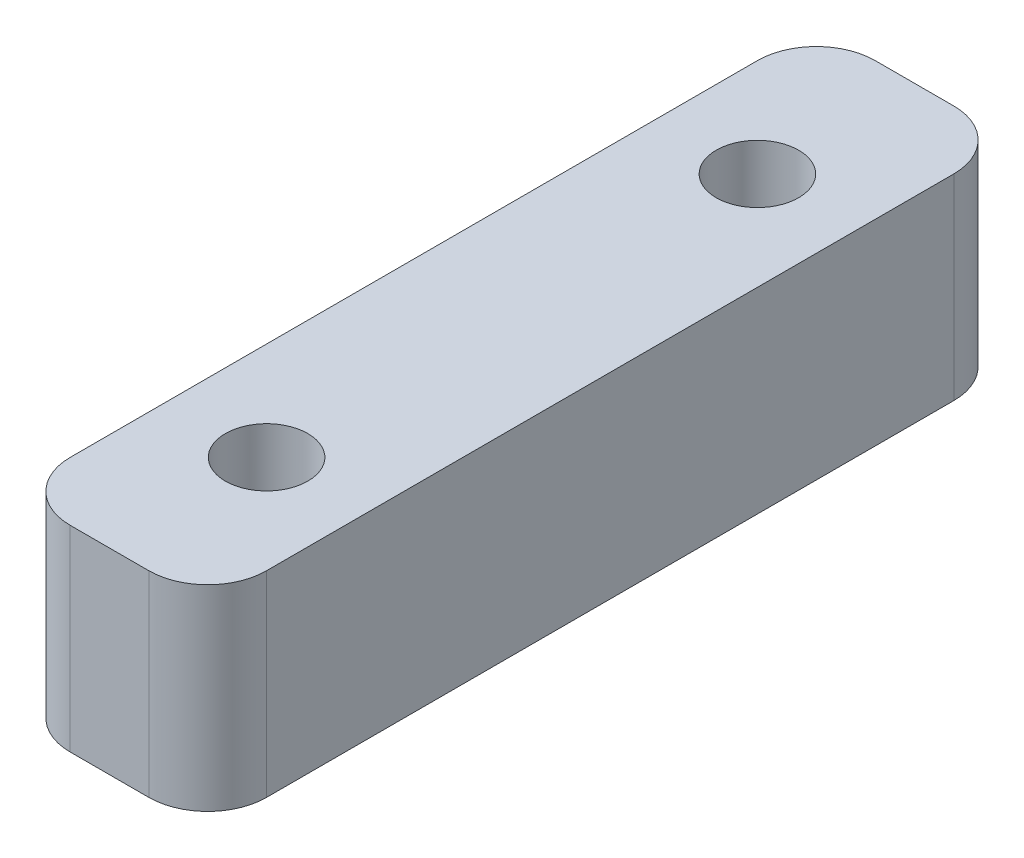
from build123d import *

# Parameters (mm, degrees)
SKETCH_1_W            = 55
SKETCH_1_H            = 32
SKETCH_1_R            = 2.1
EXTRUDE_1_DEPTH       = 10
SKETCH_2_W            = 55
SKETCH_2_H            = 4
EXTRUDE_2_DEPTH       = 10
SKETCH_4_R            = 2.1
SKETCH_4_R_2          = 1.6
EXTRUDE_3_DEPTH       = 10
SKETCH_6_R            = 2.1
EXTRUDE_4_DEPTH       = 10
SKETCH_7_W            = 15
SKETCH_7_H            = 11
CUT_EXTRUDE_1_DEPTH   = 11
EXTRUDE_5_DEPTH       = 10
SKETCH_9_R            = 1.5
CUT_EXTRUDE_2_DEPTH   = 11
SKETCH_10_OUTSIDE_W   = 301.892
SKETCH_10_OUTSIDE_H   = 218.392
SKETCH_10_OUTSIDE_W_2 = 10
SKETCH_10_OUTSIDE_H_2 = 41
CUT_EXTRUDE_3_DEPTH   = 11
FILLET_2_R            = 3


with BuildPart() as part:
    # 草图1 → 凸台-拉伸1 (new body)
    with BuildSketch(Plane(origin=(0, 0, 0), x_dir=(1, 0, 0), z_dir=(0, 1, 0))):
        Rectangle(SKETCH_1_W, SKETCH_1_H)
        with Locations((-12.5, 10)):
            Circle(SKETCH_1_R, mode=Mode.SUBTRACT)
        with Locations((12.5, 10)):
            Circle(SKETCH_1_R, mode=Mode.SUBTRACT)
        with Locations((12.5, -10)):
            Circle(SKETCH_1_R, mode=Mode.SUBTRACT)
        with Locations((-12.5, -10)):
            Circle(SKETCH_1_R, mode=Mode.SUBTRACT)
    extrude(amount=EXTRUDE_1_DEPTH)

    # 草图2 → 凸台-拉伸2 (add)
    with BuildSketch(Plane(origin=(0, 10, 0), x_dir=(1, 0, 0), z_dir=(0, 1, 0))):
        with Locations((0, -18)):
            Rectangle(SKETCH_2_W, SKETCH_2_H)
    extrude(amount=-EXTRUDE_2_DEPTH)

    # 草图4 → 凸台-拉伸3 (add)
    with BuildSketch(Plane(origin=(0, 10, 0), x_dir=(1, 0, 0), z_dir=(0, 1, 0))):
        Polygon((-27.5, -20), (-27.5, -57), (-67.5, -57), (-67.5, -98), (67.5, -98), (67.5, -57), (27.5, -57), (27.5, -20), align=None)
        with Locations((-47.5, -65)):
            Circle(SKETCH_4_R, mode=Mode.SUBTRACT)
        with Locations((-47.5, -90)):
            Circle(SKETCH_4_R, mode=Mode.SUBTRACT)
        with Locations((47.5, -90)):
            Circle(SKETCH_4_R, mode=Mode.SUBTRACT)
        with Locations((47.5, -65)):
            Circle(SKETCH_4_R, mode=Mode.SUBTRACT)
        with Locations((-62, -88)):
            Circle(SKETCH_4_R_2, mode=Mode.SUBTRACT)
        with Locations((-62, -80)):
            Circle(SKETCH_4_R_2, mode=Mode.SUBTRACT)
        with Locations((62, -88)):
            Circle(SKETCH_4_R_2, mode=Mode.SUBTRACT)
        with Locations((62, -80)):
            Circle(SKETCH_4_R_2, mode=Mode.SUBTRACT)
    extrude(amount=-EXTRUDE_3_DEPTH)

    # 草图6 → 凸台-拉伸4 (add)
    with BuildSketch(Plane(origin=(0, 10, 0), x_dir=(1, 0, 0), z_dir=(0, 1, 0))):
        Polygon((-121, -122.5), (-105, -122.5), (-83.215535743, -68), (-67.5, -68), (-67.5, -98), (-89, -142.5), (-121, -142.5), align=None)
        with Locations((-115, -127.5)):
            Circle(SKETCH_6_R, mode=Mode.SUBTRACT)
        with Locations((-95, -127.5)):
            Circle(SKETCH_6_R, mode=Mode.SUBTRACT)
        with Locations((-95, -137.5)):
            Circle(SKETCH_6_R, mode=Mode.SUBTRACT)
        with Locations((-115, -137.5)):
            Circle(SKETCH_6_R, mode=Mode.SUBTRACT)
        Polygon((67.5, -68), (83.215535743, -68), (105, -122.5), (121, -122.5), (121, -142.5), (89, -142.5), (67.5, -98), align=None)
        with Locations((115, -137.5)):
            Circle(SKETCH_6_R, mode=Mode.SUBTRACT)
        with Locations((95, -137.5)):
            Circle(SKETCH_6_R, mode=Mode.SUBTRACT)
        with Locations((95, -127.5)):
            Circle(SKETCH_6_R, mode=Mode.SUBTRACT)
        with Locations((115, -127.5)):
            Circle(SKETCH_6_R, mode=Mode.SUBTRACT)
    extrude(amount=-EXTRUDE_4_DEPTH)

    # 草图7 → 切除-拉伸1 (cut, through all)
    with BuildSketch(Plane(origin=(0, 10, 0), x_dir=(1, 0, 0), z_dir=(0, 1, 0))):
        with Locations((-60, -62.5)):
            Rectangle(SKETCH_7_W, SKETCH_7_H)
        with Locations((60, -62.5)):
            Rectangle(SKETCH_7_W, SKETCH_7_H)
    extrude(amount=-CUT_EXTRUDE_1_DEPTH, mode=Mode.SUBTRACT)

    # 草图8 → 凸台-拉伸5 (add)
    with BuildSketch(Plane(origin=(0, 10, 0), x_dir=(1, 0, 0), z_dir=(0, 1, 0))):
        Polygon((-27.5, -20), (-39.5, -57), (-27.5, -57), align=None)
        Polygon((39.5, -57), (27.5, -57), (27.5, -20), align=None)
    extrude(amount=-EXTRUDE_5_DEPTH)

    # 草图9 → 切除-拉伸2 (cut, through all)
    with BuildSketch(Plane(origin=(0, 10, 0), x_dir=(1, 0, 0), z_dir=(0, 1, 0))):
        with Locations((-30, -67)):
            Circle(SKETCH_9_R)
        with Locations((-15, -67)):
            Circle(SKETCH_9_R)
        with Locations((15, -67)):
            Circle(SKETCH_9_R)
        with Locations((30, -67)):
            Circle(SKETCH_9_R)
    extrude(amount=-CUT_EXTRUDE_2_DEPTH, mode=Mode.SUBTRACT)

    # 草图10 outside → 切除-拉伸3 (cut, through all)
    with BuildSketch(Plane(origin=(0, 10, 0), x_dir=(1, 0, 0), z_dir=(0, 1, 0))):
        with Locations((0, -63.25)):
            Rectangle(SKETCH_10_OUTSIDE_W, SKETCH_10_OUTSIDE_H)
        with Locations((-47.5, -77.5)):
            Rectangle(SKETCH_10_OUTSIDE_W_2, SKETCH_10_OUTSIDE_H_2, mode=Mode.SUBTRACT)
    extrude(amount=-CUT_EXTRUDE_3_DEPTH, mode=Mode.SUBTRACT)

    # 圆角2
    fillet_2_edges = [part.edges().sort_by_distance(p)[0] for p in [
        (-52.5, 5, 57),
        (-42.5, 5, 57),
        (-42.5, 5, 98),
        (-52.5, 5, 98),
    ]]
    fillet(fillet_2_edges, radius=FILLET_2_R)


solid = part.part
